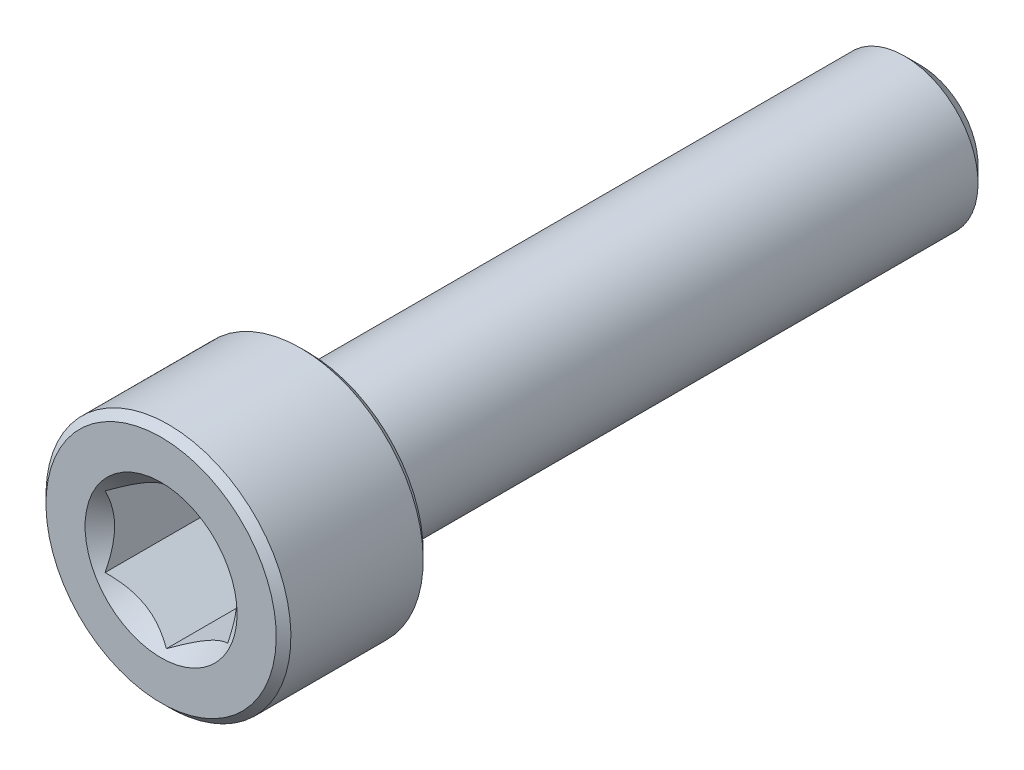
from build123d import *

# Parameters (mm, degrees)
CUT_EXTRUDE1_DEPTH = 5
SKETCH4_R          = 3.103257697
CUT_EXTRUDE2_DEPTH = 5
CUT_EXTRUDE2_DRAFT = -45


with BuildPart() as part:
    # Sketch2 → Revolve1 (revolve)
    with BuildSketch(Plane(origin=(0, 0, 0), x_dir=(0, 0, -1), z_dir=(1, 0, 0))):
        with BuildLine():
            Line((-15.5, 0), (-15.5, 4.7))
            Line((-15.5, 4.7), (-15.2, 5))
            Line((-15.2, 5), (-9.8, 5))
            Line((-9.8, 5), (-9.5, 4.7))
            Line((-9.5, 4.7), (-9.5, 3.3))
            ThreePointArc((-9.5, 3.3), (-9.412132034, 3.087867966), (-9.2, 3))
            Line((-9.2, 3), (14.850480947, 3))
            Line((14.850480947, 3), (15.5, 2.350480947))
            Line((15.5, 2.350480947), (15.5, 0))
            Line((15.5, 0), (-15.5, 0))
        make_face()
    revolve(axis=Axis((0, 0, -15.5), (0, 0, 1)))

    # Sketch3 → Cut-Extrude1 (cut)
    with BuildSketch(Plane.XY.offset(15.5)):
        Polygon((2.5, -1.443375673), (2.5, 1.443375673), (0, 2.886751346), (-2.5, 1.443375673), (-2.5, -1.443375673), (0, -2.886751346), align=None)
    extrude(amount=-CUT_EXTRUDE1_DEPTH, mode=Mode.SUBTRACT)


with BuildPart() as cut_extrude2_tool:
    # Sketch4 → Cut-Extrude2 (with draft: the straight prism first)
    with BuildSketch(Plane.XY.offset(15.5)):
        Circle(SKETCH4_R)
    extrude(amount=-CUT_EXTRUDE2_DEPTH)
    # Cut-Extrude2: the draft: its side faces are tilted about the plane it starts from
    cut_extrude2_sides = [cut_extrude2_tool.faces().sort_by_distance(p)[0] for p in [
        (-3.103257697, 0, 13),
    ]]
    draft(cut_extrude2_sides, Plane.XY.offset(15.5), CUT_EXTRUDE2_DRAFT)


with BuildPart() as part_1:
    add(part.part)

    # Cut-Extrude2: cut by cut_extrude2_tool
    add(cut_extrude2_tool.part, mode=Mode.SUBTRACT)


solid = part_1.part
